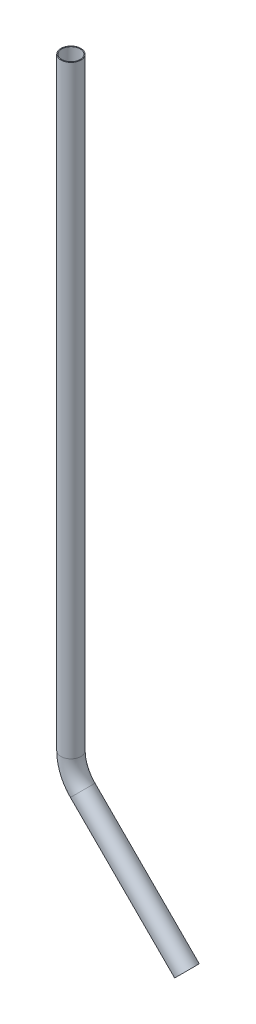
from build123d import *

# Parameters (mm, degrees)
SKETCH2_R   = 9.525
SKETCH2_R_2 = 8.7122


with BuildPart() as part:
    # Sweep1: sweep along a path in Sketch1
    with BuildLine(Plane.XY) as sweep1_path:
        Line((-1.817951031, -173.080098969), (-100.600768363, -74.297281637))
        ThreePointArc((-100.600768363, -74.297281637), (-108.859810189, -61.936752047), (-111.76, -47.356513274))
        Line((-111.76, -47.356513274), (-111.76, 524.143486726))
    # Sketch2 → Sweep1 (sweep)
    with BuildSketch(Plane(origin=(0, 0, 0), x_dir=(1, 0, 0), z_dir=(0, 1, 0))):
        with Locations((-111.76, 0)):
            Circle(SKETCH2_R)
        with Locations((-111.76, 0)):
            Circle(SKETCH2_R_2, mode=Mode.SUBTRACT)
    sweep(path=sweep1_path.line)


solid = part.part
